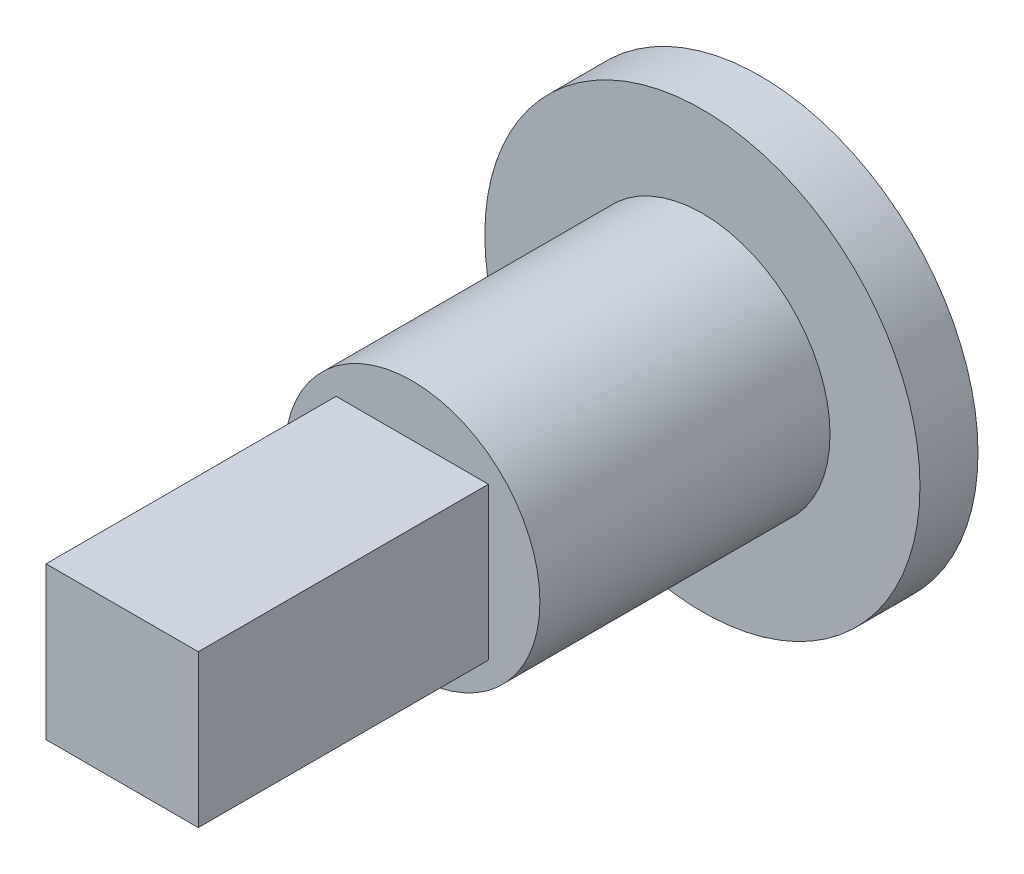
from build123d import *

# Parameters (mm, degrees)
SKETCH1_R           = 4.4
BOSS_EXTRUDE1_DEPTH = 10
SKETCH2_W           = 5.25
SKETCH2_H           = 5.25
BOSS_EXTRUDE2_DEPTH = 10
SKETCH3_R           = 7.5
BOSS_EXTRUDE3_DEPTH = 2


with BuildPart() as part:
    # Sketch1 → Boss-Extrude1 (new body)
    with BuildSketch(Plane.XY):
        Circle(SKETCH1_R)
    extrude(amount=BOSS_EXTRUDE1_DEPTH)

    # Sketch2 → Boss-Extrude2 (add)
    with BuildSketch(Plane.XY.offset(10)):
        Rectangle(SKETCH2_W, SKETCH2_H)
    extrude(amount=BOSS_EXTRUDE2_DEPTH)

    # Sketch3 → Boss-Extrude3 (add)
    with BuildSketch(Plane(origin=(0, 0, 0), x_dir=(-1, 0, 0), z_dir=(0, 0, -1))):
        Circle(SKETCH3_R)
    extrude(amount=BOSS_EXTRUDE3_DEPTH)


solid = part.part
